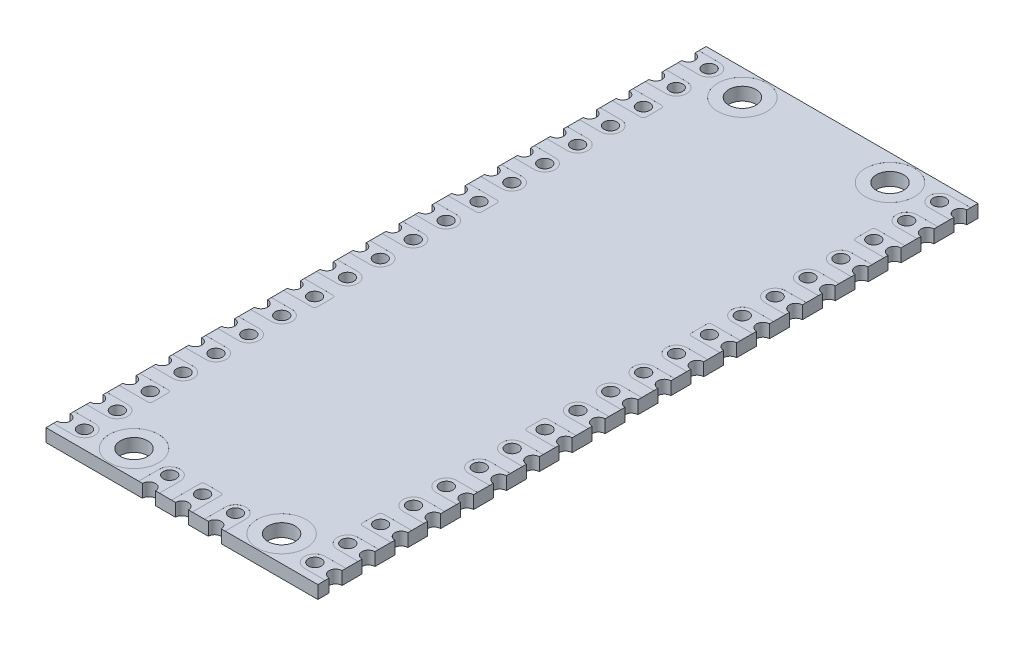
from build123d import *

# Parameters (mm, degrees)
BASES_W                        = 21
BASES_H                        = 51
BASE_DEPTH                     = 0.5
F_1_0_1_DIAMETER_HOLE1_D       = 1
HOLEHORZLP_COUNT               = 2
HOLEHORZLP_PITCH               = 1.6
SLOTCUT_DEPTH                  = 0.001
HOLEHORZLPSLOTLP_COUNT         = 20
HOLEHORZLPSLOTLP_PITCH         = 2.54
HOLEHORZLPSLOTLP_COPY_1_D      = 1
HOLEHORZLPSLOTLP_COPY_2_D      = 1
HOLEHORZLPSLOTLP_COPY_3_D      = 1
HOLEHORZLPSLOTLP_COPY_4_D      = 1
HOLEHORZLPSLOTLP_COPY_5_D      = 1
HOLEHORZLPSLOTLP_COPY_6_D      = 1
HOLEHORZLPSLOTLP_COPY_7_D      = 1
HOLEHORZLPSLOTLP_COPY_8_D      = 1
HOLEHORZLPSLOTLP_COPY_9_D      = 1
HOLEHORZLPSLOTLP_COPY_10_D     = 1
HOLEHORZLPSLOTLP_COPY_11_D     = 1
HOLEHORZLPSLOTLP_COPY_12_D     = 1
HOLEHORZLPSLOTLP_COPY_13_D     = 1
HOLEHORZLPSLOTLP_COPY_14_D     = 1
HOLEHORZLPSLOTLP_COPY_15_D     = 1
HOLEHORZLPSLOTLP_COPY_16_D     = 1
HOLEHORZLPSLOTLP_COPY_17_D     = 1
HOLEHORZLPSLOTLP_COPY_18_D     = 1
HOLEHORZLPSLOTLP_COPY_19_D     = 1
SHLPHM_COPY_1_D                = 1
SHLPHM_COPY_2_D                = 1
SHLPHM_COPY_3_D                = 1
SHLPHM_COPY_4_D                = 1
SHLPHM_COPY_5_D                = 1
SHLPHM_COPY_6_D                = 1
SHLPHM_COPY_7_D                = 1
SHLPHM_COPY_8_D                = 1
SHLPHM_COPY_9_D                = 1
SHLPHM_COPY_10_D               = 1
SHLPHM_COPY_11_D               = 1
SHLPHM_COPY_12_D               = 1
SHLPHM_COPY_13_D               = 1
SHLPHM_COPY_14_D               = 1
SHLPHM_COPY_15_D               = 1
SHLPHM_COPY_16_D               = 1
SHLPHM_COPY_17_D               = 1
SHLPHM_COPY_18_D               = 1
SHLPHM_COPY_19_D               = 1
SHLPHM_COPY_20_DEPTH           = 0.001
SHLPHM_COPY_21_DEPTH           = 0.001
SHLPHM_COPY_22_DEPTH           = 0.001
SHLPHM_COPY_23_DEPTH           = 0.001
SHLPHM_COPY_24_DEPTH           = 0.001
SHLPHM_COPY_25_DEPTH           = 0.001
SHLPHM_COPY_26_DEPTH           = 0.001
SHLPHM_COPY_27_DEPTH           = 0.001
SHLPHM_COPY_28_DEPTH           = 0.001
SHLPHM_COPY_29_DEPTH           = 0.001
SHLPHM_COPY_30_DEPTH           = 0.001
SHLPHM_COPY_31_DEPTH           = 0.001
SHLPHM_COPY_32_DEPTH           = 0.001
SHLPHM_COPY_33_DEPTH           = 0.001
SHLPHM_COPY_34_DEPTH           = 0.001
SHLPHM_COPY_35_DEPTH           = 0.001
SHLPHM_COPY_36_DEPTH           = 0.001
SHLPHM_COPY_37_DEPTH           = 0.001
SHLPHM_COPY_38_DEPTH           = 0.001
SHLPHM_COPY_39_D               = 1
SHLPHM_COPY_40_D               = 1
SHLPHM_COPY_41_D               = 1
SHLPHM_COPY_42_D               = 1
SHLPHM_COPY_43_D               = 1
SHLPHM_COPY_44_D               = 1
SHLPHM_COPY_45_D               = 1
SHLPHM_COPY_46_D               = 1
SHLPHM_COPY_47_D               = 1
SHLPHM_COPY_48_D               = 1
SHLPHM_COPY_49_D               = 1
SHLPHM_COPY_50_D               = 1
SHLPHM_COPY_51_D               = 1
SHLPHM_COPY_52_D               = 1
SHLPHM_COPY_53_D               = 1
SHLPHM_COPY_54_D               = 1
SHLPHM_COPY_55_D               = 1
SHLPHM_COPY_56_D               = 1
SHLPHM_COPY_57_D               = 1
SHLPHM_COPY_58_D               = 1
F_2_1_2_1_DIAMETER_HOLE1_D     = 2.1
SOLDERING2_1MMHOLECUTOUTS_R    = 1.9
SOLDERING2_1MMHOLECUTOUT_DEPTH = 0.001
SHCHMVM_COPY_1_D               = 2.1
SHCHMVM_COPY_2_SKETCH_R        = 1.9
SHCHMVM_COPY_2_DEPTH           = 0.001
SHCTOPVM_COPY_1_SKETCH_R       = 1.9
SHCTOPVM_COPY_1_DEPTH          = 0.001
SHCTOPVM_COPY_2_D              = 2.1
SHCTOPVM_COPY_3_D              = 2.1
SHCTOPVM_COPY_4_SKETCH_R       = 1.9
SHCTOPVM_COPY_4_DEPTH          = 0.001
SHCTOPVM_COPY_5_D              = 2.1
SHCTOPVM_COPY_6_D              = 2.1
SHCTOPVM_COPY_7_SKETCH_R       = 1.9
SHCTOPVM_COPY_7_DEPTH          = 0.001
SHCTOPVM_COPY_8_D              = 2.1
SQUAREETCH_DEPTH               = 0.001
SELP_COUNT                     = 4
SELP_PITCH                     = 12.7
SELPHM_COPY_1_DEPTH            = 0.001
SELPHM_COPY_2_DEPTH            = 0.001
SELPHM_COPY_3_DEPTH            = 0.001
F_1_0_1_DIAMETER_HOLE2_D       = 1
VERTICALSLOTCUT_START          = -0.001
VERTICALSLOTCUT_DEPTH          = 0.001
DH2LP_COUNT                    = 2
DH2LP_PITCH                    = 1.6
VSCHLP_COUNT                   = 2
VSCHLP_PITCH                   = 2.54
VSCHLP_COPY_1_D                = 1
VSCHLP_COL_COUNT               = 2
VSCHLP_COL_PITCH               = 2.54
VSCHLP_COL_COPY_1_D            = 1
VERTICALSQUAREETCH_DEPTH       = 0.001
VSCHPVM_DEPTH                  = 0.001


with BuildPart() as part:
    # BaseS → Base (new body, symmetric)
    with BuildSketch(Plane(origin=(0, 0, 0), x_dir=(1, 0, 0), z_dir=(0, 1, 0))):
        Rectangle(BASES_W, BASES_H)
    extrude(amount=BASE_DEPTH, both=True)

    # Ø1.0 (1) Diameter Hole1 (through all)
    with Locations(Plane(origin=(0, 0.5, 0), x_dir=(1, 0, 0), z_dir=(0, 1, 0))):
        with Locations((-8.9, -24.13)):
            f_1_0_1_diameter_hole1 = Hole(F_1_0_1_DIAMETER_HOLE1_D / 2)

    # HoleHorzLP: Ø1.0 (1) Diameter Hole1 ×2
    with Locations(*[(-i * HOLEHORZLP_PITCH, 0, 0) for i in range(1, HOLEHORZLP_COUNT)]):
        add(f_1_0_1_diameter_hole1, mode=Mode.SUBTRACT)

    # SlotCutS → SlotCut (cut)
    with BuildSketch(Plane(origin=(0, 0.5, 0), x_dir=(1, 0, 0), z_dir=(0, 1, 0))):
        with BuildLine():
            Line((-8.9, -24.93), (-10.5, -24.93))
            ThreePointArc((-10.5, -24.93), (-11.3, -24.13), (-10.5, -23.33))
            Line((-10.5, -23.33), (-8.9, -23.33))
            ThreePointArc((-8.9, -23.33), (-8.1, -24.13), (-8.9, -24.93))
        make_face()
    slotcut = extrude(amount=-SLOTCUT_DEPTH, mode=Mode.SUBTRACT)

    # HoleHorzLPSlotLP: Ø1.0 (1) Diameter Hole1, SlotCut ×20
    with Locations(*[(0, 0, -i * HOLEHORZLPSLOTLP_PITCH) for i in range(1, HOLEHORZLPSLOTLP_COUNT)]):
        add(f_1_0_1_diameter_hole1, mode=Mode.SUBTRACT)
        add(slotcut, mode=Mode.SUBTRACT)

    # HoleHorzLPSlotLP copy 1 (through all)
    with Locations(Plane(origin=(-1.6, 0.5, -2.54), x_dir=(1, 0, 0), z_dir=(0, 1, 0))):
        with Locations((-8.9, -24.13)):
            Hole(HOLEHORZLPSLOTLP_COPY_1_D / 2)

    # HoleHorzLPSlotLP copy 2 (through all)
    with Locations(Plane(origin=(-1.6, 0.5, -5.08), x_dir=(1, 0, 0), z_dir=(0, 1, 0))):
        with Locations((-8.9, -24.13)):
            Hole(HOLEHORZLPSLOTLP_COPY_2_D / 2)

    # HoleHorzLPSlotLP copy 3 (through all)
    with Locations(Plane(origin=(-1.6, 0.5, -7.62), x_dir=(1, 0, 0), z_dir=(0, 1, 0))):
        with Locations((-8.9, -24.13)):
            Hole(HOLEHORZLPSLOTLP_COPY_3_D / 2)

    # HoleHorzLPSlotLP copy 4 (through all)
    with Locations(Plane(origin=(-1.6, 0.5, -10.16), x_dir=(1, 0, 0), z_dir=(0, 1, 0))):
        with Locations((-8.9, -24.13)):
            Hole(HOLEHORZLPSLOTLP_COPY_4_D / 2)

    # HoleHorzLPSlotLP copy 5 (through all)
    with Locations(Plane(origin=(-1.6, 0.5, -12.7), x_dir=(1, 0, 0), z_dir=(0, 1, 0))):
        with Locations((-8.9, -24.13)):
            Hole(HOLEHORZLPSLOTLP_COPY_5_D / 2)

    # HoleHorzLPSlotLP copy 6 (through all)
    with Locations(Plane(origin=(-1.6, 0.5, -15.24), x_dir=(1, 0, 0), z_dir=(0, 1, 0))):
        with Locations((-8.9, -24.13)):
            Hole(HOLEHORZLPSLOTLP_COPY_6_D / 2)

    # HoleHorzLPSlotLP copy 7 (through all)
    with Locations(Plane(origin=(-1.6, 0.5, -17.78), x_dir=(1, 0, 0), z_dir=(0, 1, 0))):
        with Locations((-8.9, -24.13)):
            Hole(HOLEHORZLPSLOTLP_COPY_7_D / 2)

    # HoleHorzLPSlotLP copy 8 (through all)
    with Locations(Plane(origin=(-1.6, 0.5, -20.32), x_dir=(1, 0, 0), z_dir=(0, 1, 0))):
        with Locations((-8.9, -24.13)):
            Hole(HOLEHORZLPSLOTLP_COPY_8_D / 2)

    # HoleHorzLPSlotLP copy 9 (through all)
    with Locations(Plane(origin=(-1.6, 0.5, -22.86), x_dir=(1, 0, 0), z_dir=(0, 1, 0))):
        with Locations((-8.9, -24.13)):
            Hole(HOLEHORZLPSLOTLP_COPY_9_D / 2)

    # HoleHorzLPSlotLP copy 10 (through all)
    with Locations(Plane(origin=(-1.6, 0.5, -25.4), x_dir=(1, 0, 0), z_dir=(0, 1, 0))):
        with Locations((-8.9, -24.13)):
            Hole(HOLEHORZLPSLOTLP_COPY_10_D / 2)

    # HoleHorzLPSlotLP copy 11 (through all)
    with Locations(Plane(origin=(-1.6, 0.5, -27.94), x_dir=(1, 0, 0), z_dir=(0, 1, 0))):
        with Locations((-8.9, -24.13)):
            Hole(HOLEHORZLPSLOTLP_COPY_11_D / 2)

    # HoleHorzLPSlotLP copy 12 (through all)
    with Locations(Plane(origin=(-1.6, 0.5, -30.48), x_dir=(1, 0, 0), z_dir=(0, 1, 0))):
        with Locations((-8.9, -24.13)):
            Hole(HOLEHORZLPSLOTLP_COPY_12_D / 2)

    # HoleHorzLPSlotLP copy 13 (through all)
    with Locations(Plane(origin=(-1.6, 0.5, -33.02), x_dir=(1, 0, 0), z_dir=(0, 1, 0))):
        with Locations((-8.9, -24.13)):
            Hole(HOLEHORZLPSLOTLP_COPY_13_D / 2)

    # HoleHorzLPSlotLP copy 14 (through all)
    with Locations(Plane(origin=(-1.6, 0.5, -35.56), x_dir=(1, 0, 0), z_dir=(0, 1, 0))):
        with Locations((-8.9, -24.13)):
            Hole(HOLEHORZLPSLOTLP_COPY_14_D / 2)

    # HoleHorzLPSlotLP copy 15 (through all)
    with Locations(Plane(origin=(-1.6, 0.5, -38.1), x_dir=(1, 0, 0), z_dir=(0, 1, 0))):
        with Locations((-8.9, -24.13)):
            Hole(HOLEHORZLPSLOTLP_COPY_15_D / 2)

    # HoleHorzLPSlotLP copy 16 (through all)
    with Locations(Plane(origin=(-1.6, 0.5, -40.64), x_dir=(1, 0, 0), z_dir=(0, 1, 0))):
        with Locations((-8.9, -24.13)):
            Hole(HOLEHORZLPSLOTLP_COPY_16_D / 2)

    # HoleHorzLPSlotLP copy 17 (through all)
    with Locations(Plane(origin=(-1.6, 0.5, -43.18), x_dir=(1, 0, 0), z_dir=(0, 1, 0))):
        with Locations((-8.9, -24.13)):
            Hole(HOLEHORZLPSLOTLP_COPY_17_D / 2)

    # HoleHorzLPSlotLP copy 18 (through all)
    with Locations(Plane(origin=(-1.6, 0.5, -45.72), x_dir=(1, 0, 0), z_dir=(0, 1, 0))):
        with Locations((-8.9, -24.13)):
            Hole(HOLEHORZLPSLOTLP_COPY_18_D / 2)

    # HoleHorzLPSlotLP copy 19 (through all)
    with Locations(Plane(origin=(-1.6, 0.5, -48.26), x_dir=(1, 0, 0), z_dir=(0, 1, 0))):
        with Locations((-8.9, -24.13)):
            Hole(HOLEHORZLPSLOTLP_COPY_19_D / 2)

    # SHLPHM: Ø1.0 (1) Diameter Hole1, SlotCut across plane
    add(f_1_0_1_diameter_hole1.mirror(Plane(origin=(0, 0, 0), x_dir=(0, 0, 1), z_dir=(1, 0, 0))), mode=Mode.SUBTRACT)
    add(slotcut.mirror(Plane(origin=(0, 0, 0), x_dir=(0, 0, 1), z_dir=(1, 0, 0))), mode=Mode.SUBTRACT)

    # SHLPHM copy 1 (through all)
    with Locations(Plane(origin=(0, 0.5, -2.54), x_dir=(-1, 0, 0), z_dir=(0, 1, 0))):
        with Locations((-8.9, 24.13)):
            Hole(SHLPHM_COPY_1_D / 2)

    # SHLPHM copy 2 (through all)
    with Locations(Plane(origin=(0, 0.5, -5.08), x_dir=(-1, 0, 0), z_dir=(0, 1, 0))):
        with Locations((-8.9, 24.13)):
            Hole(SHLPHM_COPY_2_D / 2)

    # SHLPHM copy 3 (through all)
    with Locations(Plane(origin=(0, 0.5, -7.62), x_dir=(-1, 0, 0), z_dir=(0, 1, 0))):
        with Locations((-8.9, 24.13)):
            Hole(SHLPHM_COPY_3_D / 2)

    # SHLPHM copy 4 (through all)
    with Locations(Plane(origin=(0, 0.5, -10.16), x_dir=(-1, 0, 0), z_dir=(0, 1, 0))):
        with Locations((-8.9, 24.13)):
            Hole(SHLPHM_COPY_4_D / 2)

    # SHLPHM copy 5 (through all)
    with Locations(Plane(origin=(0, 0.5, -12.7), x_dir=(-1, 0, 0), z_dir=(0, 1, 0))):
        with Locations((-8.9, 24.13)):
            Hole(SHLPHM_COPY_5_D / 2)

    # SHLPHM copy 6 (through all)
    with Locations(Plane(origin=(0, 0.5, -15.24), x_dir=(-1, 0, 0), z_dir=(0, 1, 0))):
        with Locations((-8.9, 24.13)):
            Hole(SHLPHM_COPY_6_D / 2)

    # SHLPHM copy 7 (through all)
    with Locations(Plane(origin=(0, 0.5, -17.78), x_dir=(-1, 0, 0), z_dir=(0, 1, 0))):
        with Locations((-8.9, 24.13)):
            Hole(SHLPHM_COPY_7_D / 2)

    # SHLPHM copy 8 (through all)
    with Locations(Plane(origin=(0, 0.5, -20.32), x_dir=(-1, 0, 0), z_dir=(0, 1, 0))):
        with Locations((-8.9, 24.13)):
            Hole(SHLPHM_COPY_8_D / 2)

    # SHLPHM copy 9 (through all)
    with Locations(Plane(origin=(0, 0.5, -22.86), x_dir=(-1, 0, 0), z_dir=(0, 1, 0))):
        with Locations((-8.9, 24.13)):
            Hole(SHLPHM_COPY_9_D / 2)

    # SHLPHM copy 10 (through all)
    with Locations(Plane(origin=(0, 0.5, -25.4), x_dir=(-1, 0, 0), z_dir=(0, 1, 0))):
        with Locations((-8.9, 24.13)):
            Hole(SHLPHM_COPY_10_D / 2)

    # SHLPHM copy 11 (through all)
    with Locations(Plane(origin=(0, 0.5, -27.94), x_dir=(-1, 0, 0), z_dir=(0, 1, 0))):
        with Locations((-8.9, 24.13)):
            Hole(SHLPHM_COPY_11_D / 2)

    # SHLPHM copy 12 (through all)
    with Locations(Plane(origin=(0, 0.5, -30.48), x_dir=(-1, 0, 0), z_dir=(0, 1, 0))):
        with Locations((-8.9, 24.13)):
            Hole(SHLPHM_COPY_12_D / 2)

    # SHLPHM copy 13 (through all)
    with Locations(Plane(origin=(0, 0.5, -33.02), x_dir=(-1, 0, 0), z_dir=(0, 1, 0))):
        with Locations((-8.9, 24.13)):
            Hole(SHLPHM_COPY_13_D / 2)

    # SHLPHM copy 14 (through all)
    with Locations(Plane(origin=(0, 0.5, -35.56), x_dir=(-1, 0, 0), z_dir=(0, 1, 0))):
        with Locations((-8.9, 24.13)):
            Hole(SHLPHM_COPY_14_D / 2)

    # SHLPHM copy 15 (through all)
    with Locations(Plane(origin=(0, 0.5, -38.1), x_dir=(-1, 0, 0), z_dir=(0, 1, 0))):
        with Locations((-8.9, 24.13)):
            Hole(SHLPHM_COPY_15_D / 2)

    # SHLPHM copy 16 (through all)
    with Locations(Plane(origin=(0, 0.5, -40.64), x_dir=(-1, 0, 0), z_dir=(0, 1, 0))):
        with Locations((-8.9, 24.13)):
            Hole(SHLPHM_COPY_16_D / 2)

    # SHLPHM copy 17 (through all)
    with Locations(Plane(origin=(0, 0.5, -43.18), x_dir=(-1, 0, 0), z_dir=(0, 1, 0))):
        with Locations((-8.9, 24.13)):
            Hole(SHLPHM_COPY_17_D / 2)

    # SHLPHM copy 18 (through all)
    with Locations(Plane(origin=(0, 0.5, -45.72), x_dir=(-1, 0, 0), z_dir=(0, 1, 0))):
        with Locations((-8.9, 24.13)):
            Hole(SHLPHM_COPY_18_D / 2)

    # SHLPHM copy 19 (through all)
    with Locations(Plane(origin=(0, 0.5, -48.26), x_dir=(-1, 0, 0), z_dir=(0, 1, 0))):
        with Locations((-8.9, 24.13)):
            Hole(SHLPHM_COPY_19_D / 2)

    # SHLPHM copy 20 sketch → SHLPHM copy 20 (cut)
    with BuildSketch(Plane(origin=(0, 0.5, -2.54), x_dir=(-1, 0, 0), z_dir=(0, 1, 0))):
        with BuildLine():
            Line((-8.9, 24.93), (-10.5, 24.93))
            ThreePointArc((-10.5, 24.93), (-11.3, 24.13), (-10.5, 23.33))
            Line((-10.5, 23.33), (-8.9, 23.33))
            ThreePointArc((-8.9, 23.33), (-8.1, 24.13), (-8.9, 24.93))
        make_face()
    extrude(amount=-SHLPHM_COPY_20_DEPTH, mode=Mode.SUBTRACT)

    # SHLPHM copy 21 sketch → SHLPHM copy 21 (cut)
    with BuildSketch(Plane(origin=(0, 0.5, -5.08), x_dir=(-1, 0, 0), z_dir=(0, 1, 0))):
        with BuildLine():
            Line((-8.9, 24.93), (-10.5, 24.93))
            ThreePointArc((-10.5, 24.93), (-11.3, 24.13), (-10.5, 23.33))
            Line((-10.5, 23.33), (-8.9, 23.33))
            ThreePointArc((-8.9, 23.33), (-8.1, 24.13), (-8.9, 24.93))
        make_face()
    extrude(amount=-SHLPHM_COPY_21_DEPTH, mode=Mode.SUBTRACT)

    # SHLPHM copy 22 sketch → SHLPHM copy 22 (cut)
    with BuildSketch(Plane(origin=(0, 0.5, -7.62), x_dir=(-1, 0, 0), z_dir=(0, 1, 0))):
        with BuildLine():
            Line((-8.9, 24.93), (-10.5, 24.93))
            ThreePointArc((-10.5, 24.93), (-11.3, 24.13), (-10.5, 23.33))
            Line((-10.5, 23.33), (-8.9, 23.33))
            ThreePointArc((-8.9, 23.33), (-8.1, 24.13), (-8.9, 24.93))
        make_face()
    extrude(amount=-SHLPHM_COPY_22_DEPTH, mode=Mode.SUBTRACT)

    # SHLPHM copy 23 sketch → SHLPHM copy 23 (cut)
    with BuildSketch(Plane(origin=(0, 0.5, -10.16), x_dir=(-1, 0, 0), z_dir=(0, 1, 0))):
        with BuildLine():
            Line((-8.9, 24.93), (-10.5, 24.93))
            ThreePointArc((-10.5, 24.93), (-11.3, 24.13), (-10.5, 23.33))
            Line((-10.5, 23.33), (-8.9, 23.33))
            ThreePointArc((-8.9, 23.33), (-8.1, 24.13), (-8.9, 24.93))
        make_face()
    extrude(amount=-SHLPHM_COPY_23_DEPTH, mode=Mode.SUBTRACT)

    # SHLPHM copy 24 sketch → SHLPHM copy 24 (cut)
    with BuildSketch(Plane(origin=(0, 0.5, -12.7), x_dir=(-1, 0, 0), z_dir=(0, 1, 0))):
        with BuildLine():
            Line((-8.9, 24.93), (-10.5, 24.93))
            ThreePointArc((-10.5, 24.93), (-11.3, 24.13), (-10.5, 23.33))
            Line((-10.5, 23.33), (-8.9, 23.33))
            ThreePointArc((-8.9, 23.33), (-8.1, 24.13), (-8.9, 24.93))
        make_face()
    extrude(amount=-SHLPHM_COPY_24_DEPTH, mode=Mode.SUBTRACT)

    # SHLPHM copy 25 sketch → SHLPHM copy 25 (cut)
    with BuildSketch(Plane(origin=(0, 0.5, -15.24), x_dir=(-1, 0, 0), z_dir=(0, 1, 0))):
        with BuildLine():
            Line((-8.9, 24.93), (-10.5, 24.93))
            ThreePointArc((-10.5, 24.93), (-11.3, 24.13), (-10.5, 23.33))
            Line((-10.5, 23.33), (-8.9, 23.33))
            ThreePointArc((-8.9, 23.33), (-8.1, 24.13), (-8.9, 24.93))
        make_face()
    extrude(amount=-SHLPHM_COPY_25_DEPTH, mode=Mode.SUBTRACT)

    # SHLPHM copy 26 sketch → SHLPHM copy 26 (cut)
    with BuildSketch(Plane(origin=(0, 0.5, -17.78), x_dir=(-1, 0, 0), z_dir=(0, 1, 0))):
        with BuildLine():
            Line((-8.9, 24.93), (-10.5, 24.93))
            ThreePointArc((-10.5, 24.93), (-11.3, 24.13), (-10.5, 23.33))
            Line((-10.5, 23.33), (-8.9, 23.33))
            ThreePointArc((-8.9, 23.33), (-8.1, 24.13), (-8.9, 24.93))
        make_face()
    extrude(amount=-SHLPHM_COPY_26_DEPTH, mode=Mode.SUBTRACT)

    # SHLPHM copy 27 sketch → SHLPHM copy 27 (cut)
    with BuildSketch(Plane(origin=(0, 0.5, -20.32), x_dir=(-1, 0, 0), z_dir=(0, 1, 0))):
        with BuildLine():
            Line((-8.9, 24.93), (-10.5, 24.93))
            ThreePointArc((-10.5, 24.93), (-11.3, 24.13), (-10.5, 23.33))
            Line((-10.5, 23.33), (-8.9, 23.33))
            ThreePointArc((-8.9, 23.33), (-8.1, 24.13), (-8.9, 24.93))
        make_face()
    extrude(amount=-SHLPHM_COPY_27_DEPTH, mode=Mode.SUBTRACT)

    # SHLPHM copy 28 sketch → SHLPHM copy 28 (cut)
    with BuildSketch(Plane(origin=(0, 0.5, -22.86), x_dir=(-1, 0, 0), z_dir=(0, 1, 0))):
        with BuildLine():
            Line((-8.9, 24.93), (-10.5, 24.93))
            ThreePointArc((-10.5, 24.93), (-11.3, 24.13), (-10.5, 23.33))
            Line((-10.5, 23.33), (-8.9, 23.33))
            ThreePointArc((-8.9, 23.33), (-8.1, 24.13), (-8.9, 24.93))
        make_face()
    extrude(amount=-SHLPHM_COPY_28_DEPTH, mode=Mode.SUBTRACT)

    # SHLPHM copy 29 sketch → SHLPHM copy 29 (cut)
    with BuildSketch(Plane(origin=(0, 0.5, -25.4), x_dir=(-1, 0, 0), z_dir=(0, 1, 0))):
        with BuildLine():
            Line((-8.9, 24.93), (-10.5, 24.93))
            ThreePointArc((-10.5, 24.93), (-11.3, 24.13), (-10.5, 23.33))
            Line((-10.5, 23.33), (-8.9, 23.33))
            ThreePointArc((-8.9, 23.33), (-8.1, 24.13), (-8.9, 24.93))
        make_face()
    extrude(amount=-SHLPHM_COPY_29_DEPTH, mode=Mode.SUBTRACT)

    # SHLPHM copy 30 sketch → SHLPHM copy 30 (cut)
    with BuildSketch(Plane(origin=(0, 0.5, -27.94), x_dir=(-1, 0, 0), z_dir=(0, 1, 0))):
        with BuildLine():
            Line((-8.9, 24.93), (-10.5, 24.93))
            ThreePointArc((-10.5, 24.93), (-11.3, 24.13), (-10.5, 23.33))
            Line((-10.5, 23.33), (-8.9, 23.33))
            ThreePointArc((-8.9, 23.33), (-8.1, 24.13), (-8.9, 24.93))
        make_face()
    extrude(amount=-SHLPHM_COPY_30_DEPTH, mode=Mode.SUBTRACT)

    # SHLPHM copy 31 sketch → SHLPHM copy 31 (cut)
    with BuildSketch(Plane(origin=(0, 0.5, -30.48), x_dir=(-1, 0, 0), z_dir=(0, 1, 0))):
        with BuildLine():
            Line((-8.9, 24.93), (-10.5, 24.93))
            ThreePointArc((-10.5, 24.93), (-11.3, 24.13), (-10.5, 23.33))
            Line((-10.5, 23.33), (-8.9, 23.33))
            ThreePointArc((-8.9, 23.33), (-8.1, 24.13), (-8.9, 24.93))
        make_face()
    extrude(amount=-SHLPHM_COPY_31_DEPTH, mode=Mode.SUBTRACT)

    # SHLPHM copy 32 sketch → SHLPHM copy 32 (cut)
    with BuildSketch(Plane(origin=(0, 0.5, -33.02), x_dir=(-1, 0, 0), z_dir=(0, 1, 0))):
        with BuildLine():
            Line((-8.9, 24.93), (-10.5, 24.93))
            ThreePointArc((-10.5, 24.93), (-11.3, 24.13), (-10.5, 23.33))
            Line((-10.5, 23.33), (-8.9, 23.33))
            ThreePointArc((-8.9, 23.33), (-8.1, 24.13), (-8.9, 24.93))
        make_face()
    extrude(amount=-SHLPHM_COPY_32_DEPTH, mode=Mode.SUBTRACT)

    # SHLPHM copy 33 sketch → SHLPHM copy 33 (cut)
    with BuildSketch(Plane(origin=(0, 0.5, -35.56), x_dir=(-1, 0, 0), z_dir=(0, 1, 0))):
        with BuildLine():
            Line((-8.9, 24.93), (-10.5, 24.93))
            ThreePointArc((-10.5, 24.93), (-11.3, 24.13), (-10.5, 23.33))
            Line((-10.5, 23.33), (-8.9, 23.33))
            ThreePointArc((-8.9, 23.33), (-8.1, 24.13), (-8.9, 24.93))
        make_face()
    extrude(amount=-SHLPHM_COPY_33_DEPTH, mode=Mode.SUBTRACT)

    # SHLPHM copy 34 sketch → SHLPHM copy 34 (cut)
    with BuildSketch(Plane(origin=(0, 0.5, -38.1), x_dir=(-1, 0, 0), z_dir=(0, 1, 0))):
        with BuildLine():
            Line((-8.9, 24.93), (-10.5, 24.93))
            ThreePointArc((-10.5, 24.93), (-11.3, 24.13), (-10.5, 23.33))
            Line((-10.5, 23.33), (-8.9, 23.33))
            ThreePointArc((-8.9, 23.33), (-8.1, 24.13), (-8.9, 24.93))
        make_face()
    extrude(amount=-SHLPHM_COPY_34_DEPTH, mode=Mode.SUBTRACT)

    # SHLPHM copy 35 sketch → SHLPHM copy 35 (cut)
    with BuildSketch(Plane(origin=(0, 0.5, -40.64), x_dir=(-1, 0, 0), z_dir=(0, 1, 0))):
        with BuildLine():
            Line((-8.9, 24.93), (-10.5, 24.93))
            ThreePointArc((-10.5, 24.93), (-11.3, 24.13), (-10.5, 23.33))
            Line((-10.5, 23.33), (-8.9, 23.33))
            ThreePointArc((-8.9, 23.33), (-8.1, 24.13), (-8.9, 24.93))
        make_face()
    extrude(amount=-SHLPHM_COPY_35_DEPTH, mode=Mode.SUBTRACT)

    # SHLPHM copy 36 sketch → SHLPHM copy 36 (cut)
    with BuildSketch(Plane(origin=(0, 0.5, -43.18), x_dir=(-1, 0, 0), z_dir=(0, 1, 0))):
        with BuildLine():
            Line((-8.9, 24.93), (-10.5, 24.93))
            ThreePointArc((-10.5, 24.93), (-11.3, 24.13), (-10.5, 23.33))
            Line((-10.5, 23.33), (-8.9, 23.33))
            ThreePointArc((-8.9, 23.33), (-8.1, 24.13), (-8.9, 24.93))
        make_face()
    extrude(amount=-SHLPHM_COPY_36_DEPTH, mode=Mode.SUBTRACT)

    # SHLPHM copy 37 sketch → SHLPHM copy 37 (cut)
    with BuildSketch(Plane(origin=(0, 0.5, -45.72), x_dir=(-1, 0, 0), z_dir=(0, 1, 0))):
        with BuildLine():
            Line((-8.9, 24.93), (-10.5, 24.93))
            ThreePointArc((-10.5, 24.93), (-11.3, 24.13), (-10.5, 23.33))
            Line((-10.5, 23.33), (-8.9, 23.33))
            ThreePointArc((-8.9, 23.33), (-8.1, 24.13), (-8.9, 24.93))
        make_face()
    extrude(amount=-SHLPHM_COPY_37_DEPTH, mode=Mode.SUBTRACT)

    # SHLPHM copy 38 sketch → SHLPHM copy 38 (cut)
    with BuildSketch(Plane(origin=(0, 0.5, -48.26), x_dir=(-1, 0, 0), z_dir=(0, 1, 0))):
        with BuildLine():
            Line((-8.9, 24.93), (-10.5, 24.93))
            ThreePointArc((-10.5, 24.93), (-11.3, 24.13), (-10.5, 23.33))
            Line((-10.5, 23.33), (-8.9, 23.33))
            ThreePointArc((-8.9, 23.33), (-8.1, 24.13), (-8.9, 24.93))
        make_face()
    extrude(amount=-SHLPHM_COPY_38_DEPTH, mode=Mode.SUBTRACT)

    # SHLPHM copy 39 (through all)
    with Locations(Plane(origin=(1.6, 0.5, -2.54), x_dir=(-1, 0, 0), z_dir=(0, 1, 0))):
        with Locations((-8.9, 24.13)):
            Hole(SHLPHM_COPY_39_D / 2)

    # SHLPHM copy 40 (through all)
    with Locations(Plane(origin=(1.6, 0.5, -5.08), x_dir=(-1, 0, 0), z_dir=(0, 1, 0))):
        with Locations((-8.9, 24.13)):
            Hole(SHLPHM_COPY_40_D / 2)

    # SHLPHM copy 41 (through all)
    with Locations(Plane(origin=(1.6, 0.5, -7.62), x_dir=(-1, 0, 0), z_dir=(0, 1, 0))):
        with Locations((-8.9, 24.13)):
            Hole(SHLPHM_COPY_41_D / 2)

    # SHLPHM copy 42 (through all)
    with Locations(Plane(origin=(1.6, 0.5, -10.16), x_dir=(-1, 0, 0), z_dir=(0, 1, 0))):
        with Locations((-8.9, 24.13)):
            Hole(SHLPHM_COPY_42_D / 2)

    # SHLPHM copy 43 (through all)
    with Locations(Plane(origin=(1.6, 0.5, -12.7), x_dir=(-1, 0, 0), z_dir=(0, 1, 0))):
        with Locations((-8.9, 24.13)):
            Hole(SHLPHM_COPY_43_D / 2)

    # SHLPHM copy 44 (through all)
    with Locations(Plane(origin=(1.6, 0.5, -15.24), x_dir=(-1, 0, 0), z_dir=(0, 1, 0))):
        with Locations((-8.9, 24.13)):
            Hole(SHLPHM_COPY_44_D / 2)

    # SHLPHM copy 45 (through all)
    with Locations(Plane(origin=(1.6, 0.5, -17.78), x_dir=(-1, 0, 0), z_dir=(0, 1, 0))):
        with Locations((-8.9, 24.13)):
            Hole(SHLPHM_COPY_45_D / 2)

    # SHLPHM copy 46 (through all)
    with Locations(Plane(origin=(1.6, 0.5, -20.32), x_dir=(-1, 0, 0), z_dir=(0, 1, 0))):
        with Locations((-8.9, 24.13)):
            Hole(SHLPHM_COPY_46_D / 2)

    # SHLPHM copy 47 (through all)
    with Locations(Plane(origin=(1.6, 0.5, -22.86), x_dir=(-1, 0, 0), z_dir=(0, 1, 0))):
        with Locations((-8.9, 24.13)):
            Hole(SHLPHM_COPY_47_D / 2)

    # SHLPHM copy 48 (through all)
    with Locations(Plane(origin=(1.6, 0.5, -25.4), x_dir=(-1, 0, 0), z_dir=(0, 1, 0))):
        with Locations((-8.9, 24.13)):
            Hole(SHLPHM_COPY_48_D / 2)

    # SHLPHM copy 49 (through all)
    with Locations(Plane(origin=(1.6, 0.5, -27.94), x_dir=(-1, 0, 0), z_dir=(0, 1, 0))):
        with Locations((-8.9, 24.13)):
            Hole(SHLPHM_COPY_49_D / 2)

    # SHLPHM copy 50 (through all)
    with Locations(Plane(origin=(1.6, 0.5, -30.48), x_dir=(-1, 0, 0), z_dir=(0, 1, 0))):
        with Locations((-8.9, 24.13)):
            Hole(SHLPHM_COPY_50_D / 2)

    # SHLPHM copy 51 (through all)
    with Locations(Plane(origin=(1.6, 0.5, -33.02), x_dir=(-1, 0, 0), z_dir=(0, 1, 0))):
        with Locations((-8.9, 24.13)):
            Hole(SHLPHM_COPY_51_D / 2)

    # SHLPHM copy 52 (through all)
    with Locations(Plane(origin=(1.6, 0.5, -35.56), x_dir=(-1, 0, 0), z_dir=(0, 1, 0))):
        with Locations((-8.9, 24.13)):
            Hole(SHLPHM_COPY_52_D / 2)

    # SHLPHM copy 53 (through all)
    with Locations(Plane(origin=(1.6, 0.5, -38.1), x_dir=(-1, 0, 0), z_dir=(0, 1, 0))):
        with Locations((-8.9, 24.13)):
            Hole(SHLPHM_COPY_53_D / 2)

    # SHLPHM copy 54 (through all)
    with Locations(Plane(origin=(1.6, 0.5, -40.64), x_dir=(-1, 0, 0), z_dir=(0, 1, 0))):
        with Locations((-8.9, 24.13)):
            Hole(SHLPHM_COPY_54_D / 2)

    # SHLPHM copy 55 (through all)
    with Locations(Plane(origin=(1.6, 0.5, -43.18), x_dir=(-1, 0, 0), z_dir=(0, 1, 0))):
        with Locations((-8.9, 24.13)):
            Hole(SHLPHM_COPY_55_D / 2)

    # SHLPHM copy 56 (through all)
    with Locations(Plane(origin=(1.6, 0.5, -45.72), x_dir=(-1, 0, 0), z_dir=(0, 1, 0))):
        with Locations((-8.9, 24.13)):
            Hole(SHLPHM_COPY_56_D / 2)

    # SHLPHM copy 57 (through all)
    with Locations(Plane(origin=(1.6, 0.5, -48.26), x_dir=(-1, 0, 0), z_dir=(0, 1, 0))):
        with Locations((-8.9, 24.13)):
            Hole(SHLPHM_COPY_57_D / 2)

    # SHLPHM copy 58 (through all)
    with Locations(Plane(origin=(1.6, 0.5, 0), x_dir=(-1, 0, 0), z_dir=(0, 1, 0))):
        with Locations((-8.9, 24.13)):
            Hole(SHLPHM_COPY_58_D / 2)

    # Ø2.1 (2.1) Diameter Hole1 (through all)
    with Locations(Plane(origin=(0, 0.5, 0), x_dir=(1, 0, 0), z_dir=(0, 1, 0))):
        with Locations((-5.7, -23.5)):
            f_2_1_2_1_diameter_hole1 = Hole(F_2_1_2_1_DIAMETER_HOLE1_D / 2)

    # Soldering2.1mmHoleCutoutS → Soldering2.1mmHoleCutout (cut)
    with BuildSketch(Plane(origin=(0, 0.5, 0), x_dir=(1, 0, 0), z_dir=(0, 1, 0))):
        with Locations((-5.7, -23.5)):
            Circle(SOLDERING2_1MMHOLECUTOUTS_R)
    soldering2_1mmholecutout = extrude(amount=-SOLDERING2_1MMHOLECUTOUT_DEPTH, mode=Mode.SUBTRACT)

    # SHCHM: Ø2.1 (2.1) Diameter Hole1, Soldering2.1mmHoleCutout across plane
    add(f_2_1_2_1_diameter_hole1.mirror(Plane(origin=(0, 0, 0), x_dir=(0, 0, 1), z_dir=(1, 0, 0))), mode=Mode.SUBTRACT)
    add(soldering2_1mmholecutout.mirror(Plane(origin=(0, 0, 0), x_dir=(0, 0, 1), z_dir=(1, 0, 0))), mode=Mode.SUBTRACT)

    # SHCHMVM: Soldering2.1mmHoleCutout, Ø2.1 (2.1) Diameter Hole1 across plane
    add(soldering2_1mmholecutout.mirror(Plane.XY), mode=Mode.SUBTRACT)
    add(f_2_1_2_1_diameter_hole1.mirror(Plane.XY), mode=Mode.SUBTRACT)

    # SHCHMVM copy 1 (through all)
    with Locations(Plane(origin=(0, 0.5, 0), x_dir=(-1, 0, 0), z_dir=(0, 1, 0))):
        with Locations((-5.7, -23.5)):
            Hole(SHCHMVM_COPY_1_D / 2)

    # SHCHMVM copy 2 sketch → SHCHMVM copy 2 (cut)
    with BuildSketch(Plane(origin=(0, 0.5, 0), x_dir=(-1, 0, 0), z_dir=(0, 1, 0))):
        with Locations((-5.7, -23.5)):
            Circle(SHCHMVM_COPY_2_SKETCH_R)
    extrude(amount=-SHCHMVM_COPY_2_DEPTH, mode=Mode.SUBTRACT)

    # SHCTopVM: Soldering2.1mmHoleCutout across plane
    add(soldering2_1mmholecutout.mirror(Plane.ZX), mode=Mode.SUBTRACT)

    # SHCTopVM copy 1 sketch → SHCTopVM copy 1 (cut)
    with BuildSketch(Plane.XZ.offset(0.5)):
        with Locations((-5.7, -23.5)):
            Circle(SHCTOPVM_COPY_1_SKETCH_R)
    extrude(amount=-SHCTOPVM_COPY_1_DEPTH, mode=Mode.SUBTRACT)

    # SHCTopVM copy 2 (through all)
    with Locations(Plane.XZ.offset(0.5)):
        with Locations((-5.7, -23.5)):
            Hole(SHCTOPVM_COPY_2_D / 2)

    # SHCTopVM copy 3 (through all)
    with Locations(Plane(origin=(0, -0.5, 0), x_dir=(-1, 0, 0), z_dir=(0, -1, 0))):
        with Locations((-5.7, 23.5)):
            Hole(SHCTOPVM_COPY_3_D / 2)

    # SHCTopVM copy 4 sketch → SHCTopVM copy 4 (cut)
    with BuildSketch(Plane(origin=(0, -0.5, 0), x_dir=(-1, 0, 0), z_dir=(0, -1, 0))):
        with Locations((-5.7, 23.5)):
            Circle(SHCTOPVM_COPY_4_SKETCH_R)
    extrude(amount=-SHCTOPVM_COPY_4_DEPTH, mode=Mode.SUBTRACT)

    # SHCTopVM copy 5 (through all)
    with Locations(Plane.XZ.offset(0.5)):
        with Locations((-5.7, 23.5)):
            Hole(SHCTOPVM_COPY_5_D / 2)

    # SHCTopVM copy 6 (through all)
    with Locations(Plane(origin=(0, -0.5, 0), x_dir=(-1, 0, 0), z_dir=(0, -1, 0))):
        with Locations((-5.7, -23.5)):
            Hole(SHCTOPVM_COPY_6_D / 2)

    # SHCTopVM copy 7 sketch → SHCTopVM copy 7 (cut)
    with BuildSketch(Plane(origin=(0, -0.5, 0), x_dir=(-1, 0, 0), z_dir=(0, -1, 0))):
        with Locations((-5.7, -23.5)):
            Circle(SHCTOPVM_COPY_7_SKETCH_R)
    extrude(amount=-SHCTOPVM_COPY_7_DEPTH, mode=Mode.SUBTRACT)

    # SHCTopVM copy 8 (through all)
    with Locations(Plane.XZ.offset(0.5)):
        with Locations((-5.7, 23.5)):
            Hole(SHCTOPVM_COPY_8_D / 2)

    # SquareEtchS → SquareEtch (cut)
    with BuildSketch(Plane(origin=(0, 0.5, 0), x_dir=(1, 0, 0), z_dir=(0, 1, 0))):
        with BuildLine():
            Line((-10.5, -18.25), (-8.3, -18.25))
            ThreePointArc((-8.3, -18.25), (-8.158578644, -18.308578644), (-8.1, -18.45))
            Line((-8.1, -18.45), (-8.1, -19.65))
            ThreePointArc((-8.1, -19.65), (-8.158578644, -19.791421356), (-8.3, -19.85))
            Line((-8.3, -19.85), (-10.5, -19.85))
            Line((-10.5, -19.85), (-10.5, -18.25))
        make_face()
    squareetch = extrude(amount=-SQUAREETCH_DEPTH, mode=Mode.SUBTRACT)

    # SELP: SquareEtch ×4
    with Locations(*[(0, 0, -i * SELP_PITCH) for i in range(1, SELP_COUNT)]):
        add(squareetch, mode=Mode.SUBTRACT)

    # SELPHM: SquareEtch across plane
    add(squareetch.mirror(Plane(origin=(0, 0, 0), x_dir=(0, 0, 1), z_dir=(1, 0, 0))), mode=Mode.SUBTRACT)

    # SELPHM copy 1 sketch → SELPHM copy 1 (cut)
    with BuildSketch(Plane(origin=(0, 0.5, -12.7), x_dir=(-1, 0, 0), z_dir=(0, 1, 0))):
        with BuildLine():
            Line((-10.5, 18.25), (-8.3, 18.25))
            ThreePointArc((-8.3, 18.25), (-8.158578644, 18.308578644), (-8.1, 18.45))
            Line((-8.1, 18.45), (-8.1, 19.65))
            ThreePointArc((-8.1, 19.65), (-8.158578644, 19.791421356), (-8.3, 19.85))
            Line((-8.3, 19.85), (-10.5, 19.85))
            Line((-10.5, 19.85), (-10.5, 18.25))
        make_face()
    extrude(amount=-SELPHM_COPY_1_DEPTH, mode=Mode.SUBTRACT)

    # SELPHM copy 2 sketch → SELPHM copy 2 (cut)
    with BuildSketch(Plane(origin=(0, 0.5, -25.4), x_dir=(-1, 0, 0), z_dir=(0, 1, 0))):
        with BuildLine():
            Line((-10.5, 18.25), (-8.3, 18.25))
            ThreePointArc((-8.3, 18.25), (-8.158578644, 18.308578644), (-8.1, 18.45))
            Line((-8.1, 18.45), (-8.1, 19.65))
            ThreePointArc((-8.1, 19.65), (-8.158578644, 19.791421356), (-8.3, 19.85))
            Line((-8.3, 19.85), (-10.5, 19.85))
            Line((-10.5, 19.85), (-10.5, 18.25))
        make_face()
    extrude(amount=-SELPHM_COPY_2_DEPTH, mode=Mode.SUBTRACT)

    # SELPHM copy 3 sketch → SELPHM copy 3 (cut)
    with BuildSketch(Plane(origin=(0, 0.5, -38.1), x_dir=(-1, 0, 0), z_dir=(0, 1, 0))):
        with BuildLine():
            Line((-10.5, 18.25), (-8.3, 18.25))
            ThreePointArc((-8.3, 18.25), (-8.158578644, 18.308578644), (-8.1, 18.45))
            Line((-8.1, 18.45), (-8.1, 19.65))
            ThreePointArc((-8.1, 19.65), (-8.158578644, 19.791421356), (-8.3, 19.85))
            Line((-8.3, 19.85), (-10.5, 19.85))
            Line((-10.5, 19.85), (-10.5, 18.25))
        make_face()
    extrude(amount=-SELPHM_COPY_3_DEPTH, mode=Mode.SUBTRACT)

    # Ø1.0 (1) Diameter Hole2 (through all)
    with Locations(Plane(origin=(0, 0.5, 0), x_dir=(1, 0, 0), z_dir=(0, 1, 0))):
        with Locations((0, -23.9)):
            f_1_0_1_diameter_hole2 = Hole(F_1_0_1_DIAMETER_HOLE2_D / 2)

    # VerticalSlotCutS → VerticalSlotCut (cut)
    with BuildSketch(Plane(origin=(0, 0.5, 0), x_dir=(1, 0, 0), z_dir=(0, 1, 0)).offset(VERTICALSLOTCUT_START)):
        with BuildLine():
            Line((0.8, -23.9), (0.8, -25.5))
            ThreePointArc((0.8, -25.5), (0, -26.3), (-0.8, -25.5))
            Line((-0.8, -25.5), (-0.8, -23.9))
            ThreePointArc((-0.8, -23.9), (0, -23.1), (0.8, -23.9))
        make_face()
    verticalslotcut = extrude(amount=VERTICALSLOTCUT_DEPTH, mode=Mode.SUBTRACT)

    # DH2LP: Ø1.0 (1) Diameter Hole2 ×2
    with Locations(*[(0, 0, i * DH2LP_PITCH) for i in range(1, DH2LP_COUNT)]):
        add(f_1_0_1_diameter_hole2, mode=Mode.SUBTRACT)

    # VSCHLP: VerticalSlotCut, Ø1.0 (1) Diameter Hole2 ×2
    with Locations(*[(i * VSCHLP_PITCH, 0, 0) for i in range(1, VSCHLP_COUNT)]):
        add(verticalslotcut, mode=Mode.SUBTRACT)
        add(f_1_0_1_diameter_hole2, mode=Mode.SUBTRACT)

    # VSCHLP copy 1 (through all)
    with Locations(Plane(origin=(2.54, 0.5, 1.6), x_dir=(1, 0, 0), z_dir=(0, 1, 0))):
        with Locations((0, -23.9)):
            Hole(VSCHLP_COPY_1_D / 2)

    # VSCHLP col: VerticalSlotCut, Ø1.0 (1) Diameter Hole2 ×2
    with Locations(*[(-i * VSCHLP_COL_PITCH, 0, 0) for i in range(1, VSCHLP_COL_COUNT)]):
        add(verticalslotcut, mode=Mode.SUBTRACT)
        add(f_1_0_1_diameter_hole2, mode=Mode.SUBTRACT)

    # VSCHLP col copy 1 (through all)
    with Locations(Plane(origin=(-2.54, 0.5, 1.6), x_dir=(1, 0, 0), z_dir=(0, 1, 0))):
        with Locations((0, -23.9)):
            Hole(VSCHLP_COL_COPY_1_D / 2)

    # VerticalSquareEtchS → VerticalSquareEtch (cut)
    with BuildSketch(Plane(origin=(0, 0.5, 0), x_dir=(1, 0, 0), z_dir=(0, 1, 0))):
        with BuildLine():
            Line((-0.6, -23.1), (0.6, -23.1))
            ThreePointArc((0.6, -23.1), (0.741421356, -23.158578644), (0.8, -23.3))
            Line((0.8, -23.3), (0.8, -25.5))
            Line((0.8, -25.5), (-0.8, -25.5))
            Line((-0.8, -25.5), (-0.8, -23.3))
            ThreePointArc((-0.8, -23.3), (-0.741421356, -23.158578644), (-0.6, -23.1))
        make_face()
    extrude(amount=-VERTICALSQUAREETCH_DEPTH, mode=Mode.SUBTRACT)

    # VSCHPVMS → VSCHPVM (cut)
    with BuildSketch(Plane.XZ.offset(0.5)):
        with BuildLine():
            Line((3.04, 25.5), (3.34, 25.5))
            Line((3.34, 25.5), (3.34, 23.9))
            ThreePointArc((3.34, 23.9), (2.54, 23.1), (1.74, 23.9))
            Line((1.74, 23.9), (1.74, 25.5))
            Line((1.74, 25.5), (2.04, 25.5))
            ThreePointArc((2.04, 25.5), (2.54, 25), (3.04, 25.5))
        make_face()
        with BuildLine():
            Line((-2.04, 25.5), (-1.74, 25.5))
            Line((-1.74, 25.5), (-1.74, 23.9))
            ThreePointArc((-1.74, 23.9), (-2.54, 23.1), (-3.34, 23.9))
            Line((-3.34, 23.9), (-3.34, 25.5))
            Line((-3.34, 25.5), (-3.04, 25.5))
            ThreePointArc((-3.04, 25.5), (-2.54, 25), (-2.04, 25.5))
        make_face()
        with BuildLine():
            Line((0.5, 25.5), (0.8, 25.5))
            Line((0.8, 25.5), (0.8, 23.3))
            ThreePointArc((0.8, 23.3), (0.741421356, 23.158578644), (0.6, 23.1))
            Line((0.6, 23.1), (-0.6, 23.1))
            ThreePointArc((-0.6, 23.1), (-0.741421356, 23.158578644), (-0.8, 23.3))
            Line((-0.8, 23.3), (-0.8, 25.5))
            Line((-0.8, 25.5), (-0.5, 25.5))
            ThreePointArc((-0.5, 25.5), (0, 25), (0.5, 25.5))
        make_face()
    extrude(amount=-VSCHPVM_DEPTH, mode=Mode.SUBTRACT)


solid = part.part
